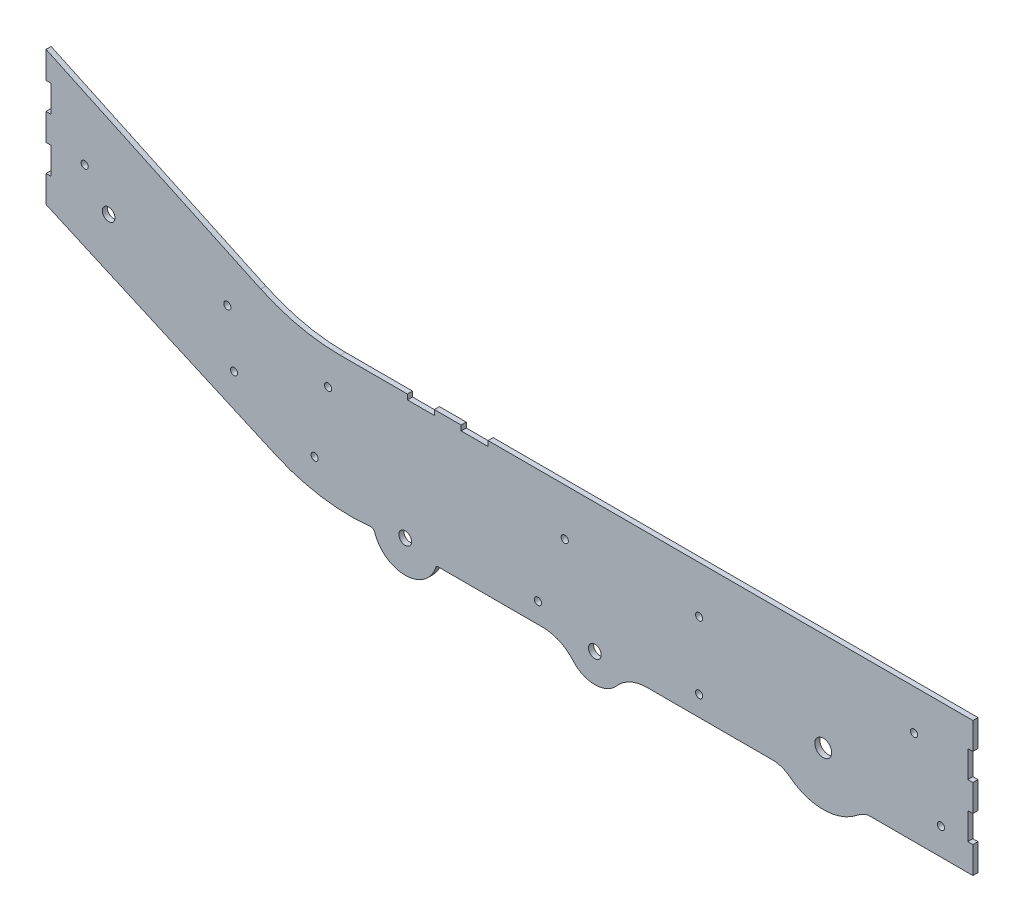
from build123d import *

# Parameters (mm, degrees)
SKETCH1_R           = 3.3782
SKETCH1_R_2         = 8.000000002
SKETCH1_R_3         = 5.999999989
SKETCH1_R_4         = 5.999999988
SKETCH1_R_5         = 6.000000014
BOSS_EXTRUDE1_DEPTH = 4.826


with BuildPart() as part:
    # Sketch1 → Boss-Extrude1 (new body)
    with BuildSketch(Plane(origin=(0, 0, 0), x_dir=(-1, 0, 0), z_dir=(0, 0, -1))):
        with BuildLine():
            Line((534.606732, 122.174), (509.206732, 122.174))
            Line((509.206732, 122.174), (509.206732, 127))
            Line((509.206732, 127), (483.806732, 127))
            Line((483.806732, 127), (483.806732, 122.174))
            Line((483.806732, 122.174), (458.406732, 122.174))
            Line((458.406732, 122.174), (458.406732, 127))
            Line((458.406732, 127), (0, 127))
            Line((0, 127), (0, 101.6))
            Line((0, 101.6), (4.826, 101.6))
            Line((4.826, 101.6), (4.826, 76.2))
            Line((4.826, 76.2), (0, 76.2))
            Line((0, 76.2), (0, 50.8))
            Line((0, 50.8), (4.826, 50.8))
            Line((4.826, 50.8), (4.826, 25.4))
            Line((4.826, 25.4), (0, 25.4))
            Line((0, 25.4), (0, 0))
            Line((0, 0), (98.996246628, 0))
            ThreePointArc((98.996246628, 0), (104.569566166, -2.09646468), (109.562810755, -5.340623016))
            ThreePointArc((109.562810755, -5.340623016), (141.115933183, -16.717309509), (172.841249368, -5.830030532))
            ThreePointArc((172.841249368, -5.830030532), (180.737693875, -1.499037017), (189.618247276, 0))
            Line((189.618247276, 0), (308.116822983, 0))
            ThreePointArc((308.116822983, 0), (323.900159152, -3.422971591), (336.847489477, -13.076834684))
            ThreePointArc((336.847489477, -13.076834684), (357.417237927, -22.434421933), (377.979766443, -13.060980118))
            ThreePointArc((377.979766443, -13.060980118), (390.895425815, -3.419107464), (406.646288314, 0))
            Line((406.646288314, 0), (506.201416447, 0))
            ThreePointArc((506.201416447, 0), (507.045954934, -0.277722975), (507.560830812, -1.002483719))
            ThreePointArc((507.560830812, -1.002483719), (536.332746766, -22.486228157), (565.609234573, -1.69532427))
            ThreePointArc((565.609234573, -1.69532427), (567.234956908, 0.389735568), (569.808214418, 0.997019206))
            ThreePointArc((569.808214418, 0.997019206), (615.71405842, 2.124494779), (659.756153394, 15.121093757))
            Line((659.756153394, 15.121093757), (876.299999975, 111.343057166))
            Line((876.299999975, 111.343057166), (876.299999975, 136.743057212))
            Line((876.299999975, 136.743057212), (871.47400014, 136.743057212))
            Line((871.47400014, 136.743057212), (871.47400014, 162.143057105))
            Line((871.47400014, 162.143057105), (876.299999975, 162.143057105))
            Line((876.299999975, 162.143057105), (876.299999975, 187.543057156))
            Line((876.299999975, 187.543057156), (871.47400014, 187.543057156))
            Line((871.47400014, 187.543057156), (871.47400014, 212.943057198))
            Line((871.47400014, 212.943057198), (876.299999975, 212.943057198))
            Line((876.299999975, 212.943057198), (876.299999975, 238.343057355))
            Line((876.299999975, 238.343057355), (673.248258968, 143.658475478))
            ThreePointArc((673.248258968, 143.658475478), (636.589695375, 131.214569938), (598.106732, 127))
            Line((598.106732, 127), (534.606732, 127))
            Line((534.606732, 127), (534.606732, 122.174))
        make_face()
        with Locations((698.5, 63.500000033)):
            Circle(SKETCH1_R, mode=Mode.SUBTRACT)
        with Locations((704.85, 114.300000033)):
            Circle(SKETCH1_R, mode=Mode.SUBTRACT)
        with Locations((30.226, 25.400000033)):
            Circle(SKETCH1_R, mode=Mode.SUBTRACT)
        with Locations((622.3, 31.750000033)):
            Circle(SKETCH1_R, mode=Mode.SUBTRACT)
        with Locations((411.2514, 19.050000033)):
            Circle(SKETCH1_R, mode=Mode.SUBTRACT)
        with Locations((385.8514, 82.550000033)):
            Circle(SKETCH1_R, mode=Mode.SUBTRACT)
        with Locations((258.8514, 82.550000033)):
            Circle(SKETCH1_R, mode=Mode.SUBTRACT)
        with Locations((258.8514, 19.050000033)):
            Circle(SKETCH1_R, mode=Mode.SUBTRACT)
        with Locations((55.626, 88.900000033)):
            Circle(SKETCH1_R, mode=Mode.SUBTRACT)
        with Locations((609.6, 95.250000033)):
            Circle(SKETCH1_R, mode=Mode.SUBTRACT)
        with Locations((839.724, 162.143057153)):
            Circle(SKETCH1_R, mode=Mode.SUBTRACT)
        with Locations((141.506729012, 33.811031431)):
            Circle(SKETCH1_R_2, mode=Mode.SUBTRACT)
        with Locations((357.406729012, 4.829371893)):
            Circle(SKETCH1_R_3, mode=Mode.SUBTRACT)
        with Locations((536.696729012, 8.009371893)):
            Circle(SKETCH1_R_4, mode=Mode.SUBTRACT)
        with Locations((817.106729012, 132.869371893)):
            Circle(SKETCH1_R_5, mode=Mode.SUBTRACT)
    extrude(amount=-BOSS_EXTRUDE1_DEPTH)


solid = part.part
